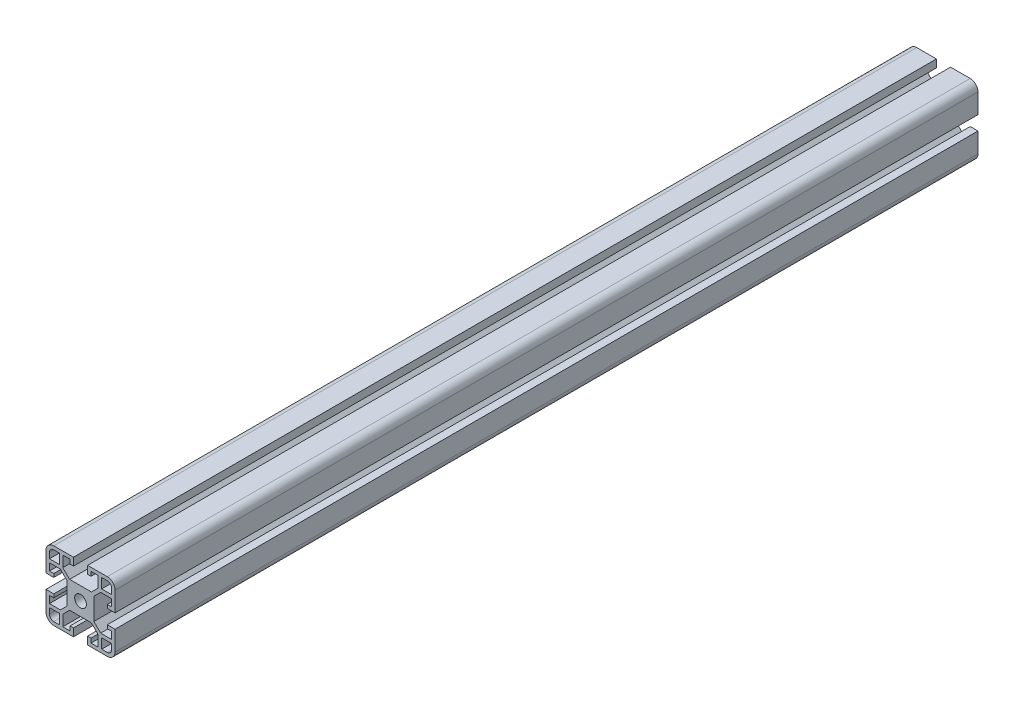
from build123d import *

# Parameters (mm, degrees)
SKETCH1_R           = 3.4
BOSS_EXTRUDE1_DEPTH = 500


with BuildPart() as part:
    # Sketch1 → Boss-Extrude1 (new body)
    with BuildSketch(Plane.XY):
        with BuildLine():
            Line((7.75, -6.335786438), (7.75, 6.335786438))
            Line((7.75, 6.335786438), (11.664213562, 10.25))
            Line((11.664213562, 10.25), (18, 10.25))
            Line((18, 10.25), (18, 6.1))
            Line((18, 6.1), (15.5, 6.1))
            Line((15.5, 6.1), (15.5, 4.1))
            Line((15.5, 4.1), (20, 4.1))
            Line((20, 4.1), (20, 15.5))
            ThreePointArc((20, 15.5), (18.681980515, 18.681980515), (15.5, 20))
            Line((15.5, 20), (4.1, 20))
            Line((4.1, 20), (4.1, 15.5))
            Line((4.1, 15.5), (6.1, 15.5))
            Line((6.1, 15.5), (6.1, 18))
            Line((6.1, 18), (10.25, 18))
            Line((10.25, 18), (10.25, 11.664213562))
            Line((10.25, 11.664213562), (6.335786438, 7.75))
            Line((6.335786438, 7.75), (-6.335786438, 7.75))
            Line((-6.335786438, 7.75), (-10.25, 11.664213562))
            Line((-10.25, 11.664213562), (-10.25, 18))
            Line((-10.25, 18), (-6.1, 18))
            Line((-6.1, 18), (-6.1, 15.5))
            Line((-6.1, 15.5), (-4.1, 15.5))
            Line((-4.1, 15.5), (-4.1, 20))
            Line((-4.1, 20), (-15.5, 20))
            ThreePointArc((-15.5, 20), (-18.681980515, 18.681980515), (-20, 15.5))
            Line((-20, 15.5), (-20, 4.1))
            Line((-20, 4.1), (-15.5, 4.1))
            Line((-15.5, 4.1), (-15.5, 6.1))
            Line((-15.5, 6.1), (-18, 6.1))
            Line((-18, 6.1), (-18, 10.25))
            Line((-18, 10.25), (-11.664213562, 10.25))
            Line((-11.664213562, 10.25), (-7.75, 6.335786438))
            Line((-7.75, 6.335786438), (-7.75, -6.335786438))
            Line((-7.75, -6.335786438), (-11.664213562, -10.25))
            Line((-11.664213562, -10.25), (-18, -10.25))
            Line((-18, -10.25), (-18, -6.1))
            Line((-18, -6.1), (-15.5, -6.1))
            Line((-15.5, -6.1), (-15.5, -4.1))
            Line((-15.5, -4.1), (-20, -4.1))
            Line((-20, -4.1), (-20, -15.5))
            ThreePointArc((-20, -15.5), (-18.681980515, -18.681980515), (-15.5, -20))
            Line((-15.5, -20), (-4.1, -20))
            Line((-4.1, -20), (-4.1, -15.5))
            Line((-4.1, -15.5), (-6.1, -15.5))
            Line((-6.1, -15.5), (-6.1, -18))
            Line((-6.1, -18), (-10.25, -18))
            Line((-10.25, -18), (-10.25, -11.664213562))
            Line((-10.25, -11.664213562), (-6.335786438, -7.75))
            Line((-6.335786438, -7.75), (6.335786438, -7.75))
            Line((6.335786438, -7.75), (10.25, -11.664213562))
            Line((10.25, -11.664213562), (10.25, -18))
            Line((10.25, -18), (6.1, -18))
            Line((6.1, -18), (6.1, -15.5))
            Line((6.1, -15.5), (4.1, -15.5))
            Line((4.1, -15.5), (4.1, -20))
            Line((4.1, -20), (15.5, -20))
            ThreePointArc((15.5, -20), (18.681980515, -18.681980515), (20, -15.5))
            Line((20, -15.5), (20, -4.1))
            Line((20, -4.1), (15.5, -4.1))
            Line((15.5, -4.1), (15.5, -6.1))
            Line((15.5, -6.1), (18, -6.1))
            Line((18, -6.1), (18, -10.25))
            Line((18, -10.25), (11.664213562, -10.25))
            Line((11.664213562, -10.25), (7.75, -6.335786438))
        make_face()
        Circle(SKETCH1_R, mode=Mode.SUBTRACT)
        with BuildLine():
            Line((15.5, 18), (12.25, 18))
            Line((12.25, 18), (12.25, 12.25))
            Line((12.25, 12.25), (18, 12.25))
            Line((18, 12.25), (18, 15.5))
            ThreePointArc((18, 15.5), (17.267766953, 17.267766953), (15.5, 18))
        make_face(mode=Mode.SUBTRACT)
        with BuildLine():
            Line((-15.5, 18), (-12.25, 18))
            Line((-12.25, 18), (-12.25, 12.25))
            Line((-12.25, 12.25), (-18, 12.25))
            Line((-18, 12.25), (-18, 15.5))
            ThreePointArc((-18, 15.5), (-17.267766953, 17.267766953), (-15.5, 18))
        make_face(mode=Mode.SUBTRACT)
        with BuildLine():
            Line((-15.5, -18), (-12.25, -18))
            Line((-12.25, -18), (-12.25, -12.25))
            Line((-12.25, -12.25), (-18, -12.25))
            Line((-18, -12.25), (-18, -15.5))
            ThreePointArc((-18, -15.5), (-17.267766953, -17.267766953), (-15.5, -18))
        make_face(mode=Mode.SUBTRACT)
        with BuildLine():
            Line((15.5, -18), (12.25, -18))
            Line((12.25, -18), (12.25, -12.25))
            Line((12.25, -12.25), (18, -12.25))
            Line((18, -12.25), (18, -15.5))
            ThreePointArc((18, -15.5), (17.267766953, -17.267766953), (15.5, -18))
        make_face(mode=Mode.SUBTRACT)
    extrude(amount=BOSS_EXTRUDE1_DEPTH)


solid = part.part
